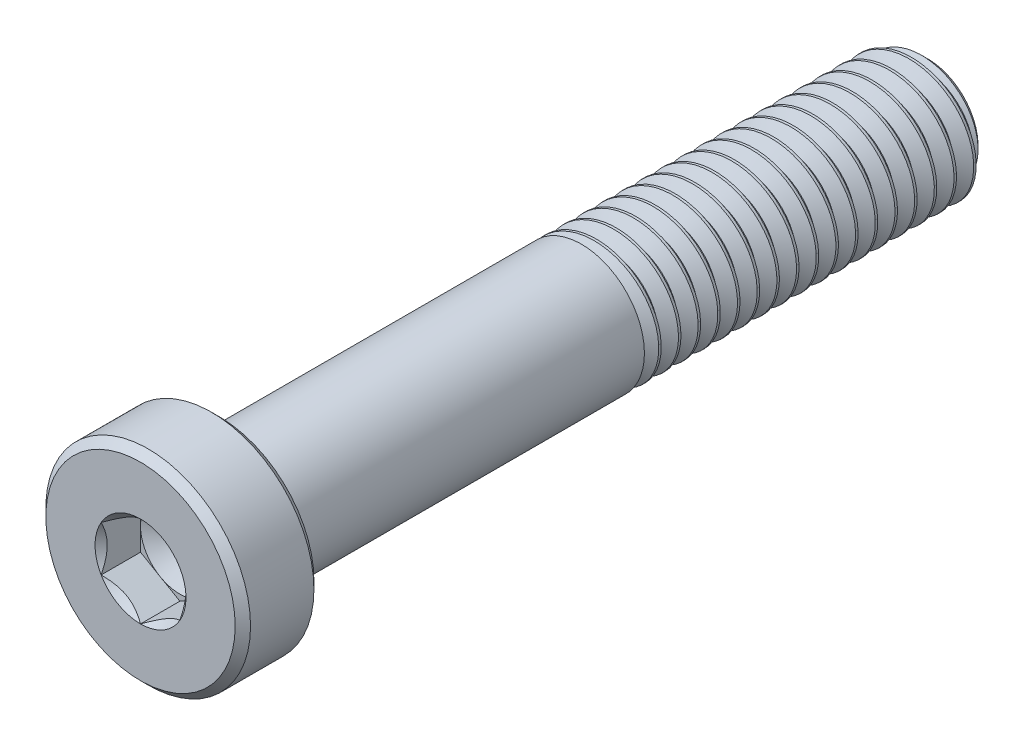
from build123d import *

# Parameters (mm, degrees)
CUT_EXTRUDE1_DEPTH     = 2.5
CUT_SWEEP1_PITCH       = 1.25
CUT_SWEEP1_HEIGHT      = 23.25
CUT_SWEEP1_RADIUS      = 4
CUT_SWEEP1_START_ANGLE = 90


with BuildPart() as part:
    # Sketch2 → Revolve1 (revolve)
    with BuildSketch(Plane(origin=(0, 0, 0), x_dir=(0, 0, -1), z_dir=(1, 0, 0)), mode=Mode.PRIVATE) as revolve1_sk:
        with BuildLine():
            Line((-20.4875, 6.5), (-20, 6.0125))
            Line((-20, 6.0125), (-20, 4.4))
            ThreePointArc((-20, 4.4), (-19.882842712, 4.117157288), (-19.6, 4))
            Line((-19.6, 4), (24.188101184, 4))
            Line((24.188101184, 4), (25, 3.188101184))
            Line((25, 3.188101184), (25, 0))
            Line((25, 0), (-22.5, 0))
            Line((-22.5, 0), (-22.5, 2.5))
            Line((-22.5, 2.5), (-25, 2.5))
            Line((-25, 2.5), (-25, 6.0125))
            Line((-25, 6.0125), (-24.5125, 6.5))
            Line((-24.5125, 6.5), (-20.4875, 6.5))
        make_face()
    revolve(revolve1_sk.sketch.rotate(Axis((0, 0, 22.5), (0, 0, -1)), 90), axis=Axis((0, 0, 22.5), (0, 0, -1)))

    # Sketch3 → Cut-Extrude1 (cut)
    with BuildSketch(Plane.XY.offset(25)):
        Polygon((0, 2.886751346), (-2.5, 1.443375673), (-2.5, -1.443375673), (0, -2.886751346), (2.5, -1.443375673), (2.5, 1.443375673), align=None)
    extrude(amount=-CUT_EXTRUDE1_DEPTH, mode=Mode.SUBTRACT)

    # Cut-Extrude2 cone 1 section (through the dimple's axis) → Cut-Extrude2 (revolve, cut)
    with BuildSketch(Plane(origin=(0, 0, 25), x_dir=(0, -1, 0), z_dir=(1, 0, 0))):
        Polygon((0, 0), (2.886751346, 0), (0, 2.886751346), align=None)
    revolve(axis=Axis((0, 0, 25), (0, 0, -1)), mode=Mode.SUBTRACT)

    # Cut-Extrude5 cone 1 section (through the dimple's axis) → Cut-Extrude5 (revolve, cut)
    with BuildSketch(Plane(origin=(0, 0, 22.5), x_dir=(0, -1, 0), z_dir=(1, 0, 0))):
        Polygon((0, 0), (2.5, 0), (0, 1.443375673), align=None)
    revolve(axis=Axis((0, 0, 22.5), (0, 0, -1)), mode=Mode.SUBTRACT)

    # Cut-Sweep1: sweep along a helix
    with BuildLine() as cut_sweep1_path:
        add(Helix(CUT_SWEEP1_PITCH, CUT_SWEEP1_HEIGHT, CUT_SWEEP1_RADIUS, center=(0, 0, -25), direction=(0, 0, 1), mode=Mode.PRIVATE).rotate(Axis((0, 0, -25), (0, 0, 1)), CUT_SWEEP1_START_ANGLE))
    # Sketch8 → Cut-Sweep1 (sweep, cut)
    with BuildSketch(Plane(origin=(0, 0, 0), x_dir=(0, 0, -1), z_dir=(1, 0, 0))):
        Polygon((24.9609375, 4.067658235), (26.1328125, 4.067658235), (25.625, 3.188101184), (25.46875, 3.188101184), align=None)
    sweep(path=cut_sweep1_path.line, is_frenet=True, mode=Mode.SUBTRACT)

    # Sketch9 → Revolve2 (revolve)
    with BuildSketch(Plane(origin=(0, 0, 0), x_dir=(0, 0, -1), z_dir=(1, 0, 0)), mode=Mode.PRIVATE) as revolve2_sk:
        Polygon((-21.056624327, 0), (-21.056624327, 4), (3, 4), (5.309401077, 0), align=None)
    revolve(revolve2_sk.sketch.rotate(Axis((0, 0, -5.309401077), (0, 0, 1)), 270), axis=Axis((0, 0, -5.309401077), (0, 0, 1)))


solid = part.part
